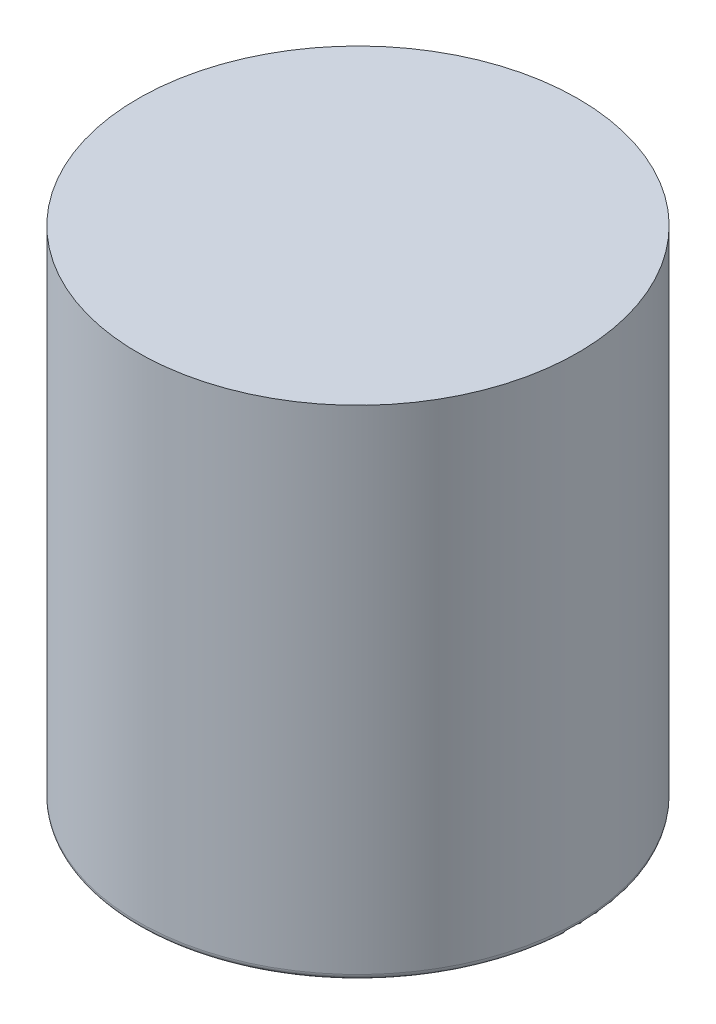
from build123d import *

# Parameters (mm, degrees)
FILLET_1_R = 0.2


with BuildPart() as part:
    # 草图1 → 旋转-薄壁1 (revolve)
    with BuildSketch(Plane.XY):
        Polygon((3.5, -11.099526066), (7.5, -11.099526066), (7.5, 5.900473934), (0, 5.900473934), (0, 5.300473934), (6.9, 5.300473934), (6.9, -10.499526066), (3.5, -10.499526066), align=None)
    revolve(axis=Axis((0, -19.840377492, 0), (0, 1, 0)))

    # 草图3 → M2 螺纹孔1 (revolve, cut)
    with BuildSketch(Plane(origin=(0, -11.099526066, -5.439713429), x_dir=(0, 0, -1), z_dir=(1, 0, 0))):
        Polygon((0, 0), (0, 2.480688495), (0.8, 2), (0.8, 0), align=None)
    hole_wizard_m2_1 = revolve(axis=Axis((0, -17.449526066, -5.439713429), (0, 1, 0)), mode=Mode.SUBTRACT)

    # 镜向1: M2 螺纹孔1 across plane
    add(hole_wizard_m2_1.mirror(Plane.XY), mode=Mode.SUBTRACT)

    # 圆角1
    fillet_1_edges = [part.edges().sort_by_distance(p)[0] for p in [
        (-7.5, -11.099526066, 0),
    ]]
    fillet(fillet_1_edges, radius=FILLET_1_R)


solid = part.part
